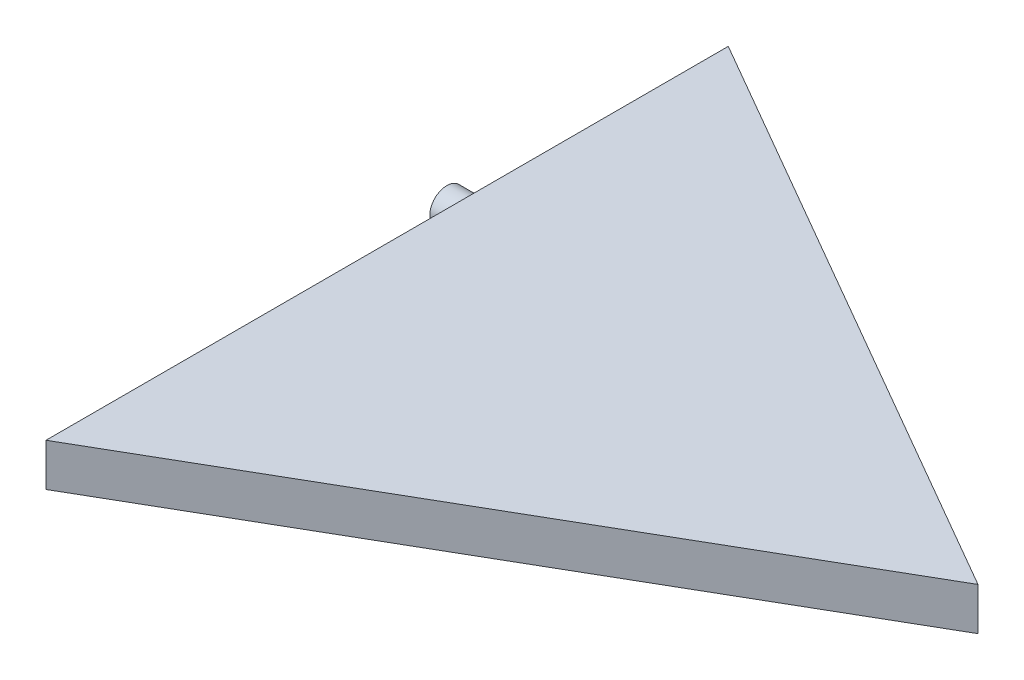
from build123d import *

# Parameters (mm, degrees)
BOSS_EXTRUDE1_DEPTH = 5
SKETCH2_R           = 2
BOSS_EXTRUDE2_DEPTH = 3


with BuildPart() as part:
    # Sketch1 → Boss-Extrude1 (new body)
    with BuildSketch(Plane(origin=(0, 0, 0), x_dir=(1, 0, 0), z_dir=(0, 1, 0))):
        Polygon((-69.282032303, 40), (0, 0), (-69.282032303, -40), align=None)
    extrude(amount=BOSS_EXTRUDE1_DEPTH)

    # Sketch2 → Boss-Extrude2 (add)
    with BuildSketch(Plane.ZY.offset(69.282032303)):
        with Locations((-10, 2.360160214)):
            Circle(SKETCH2_R)
    extrude(amount=BOSS_EXTRUDE2_DEPTH)


solid = part.part
